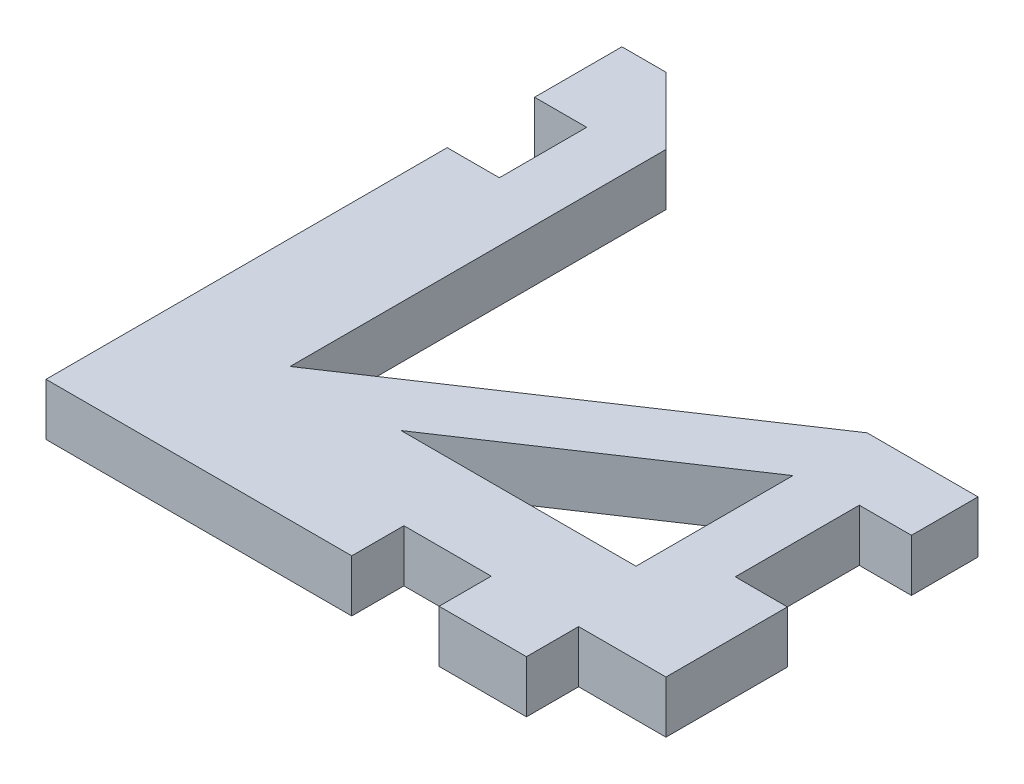
from build123d import *

# Parameters (mm, degrees)
BOSS_EXTRUDE1_DEPTH = 5.969
BOSS_EXTRUDE2_DEPTH = 5.969
SKETCH4_W           = 50.8
SKETCH4_H           = 43.029
CUT_EXTRUDE1_DEPTH  = 6.969
BOSS_EXTRUDE3_DEPTH = 5.969
BOSS_EXTRUDE5_DEPTH = 5.969
SKETCH8_W           = 10
SKETCH8_H           = 5.969
CUT_EXTRUDE2_DEPTH  = 6.969


with BuildPart() as part:
    # Sketch1 → Boss-Extrude1 (new body)
    with BuildSketch(Plane(origin=(0, 0, 0), x_dir=(1, 0, 0), z_dir=(0, 1, 0))):
        Polygon((0, 0), (-5.969, 0), (-5.969, 10), (0, 10), (0, 20), (-5.969, 20), (-5.969, 30), (-0.928040102, 30), (59.031, -29.959040102), (49.031, -29.959040102), (49.031, -35.928040102), (39.031, -35.928040102), (39.031, -29.959040102), (29.959040102, -29.959040102), align=None)
    extrude(amount=BOSS_EXTRUDE1_DEPTH)

    # Sketch3 → Boss-Extrude2 (add)
    with BuildSketch(Plane(origin=(0, 5.969, 0), x_dir=(1, 0, 0), z_dir=(0, 1, 0))):
        Polygon((6.731, -35.928040102), (29.959040102, -35.928040102), (29.959040102, -23.228040102), (6.731, 0), (-5.969, 0), (-5.969, -35.928040102), align=None)
    extrude(amount=-BOSS_EXTRUDE2_DEPTH)

    # Sketch4 → Cut-Extrude1 (cut, through all)
    with BuildSketch(Plane(origin=(0, 5.969, 0), x_dir=(1, 0, 0), z_dir=(0, 1, 0))):
        with Locations((32.131, 0.826459898)):
            Rectangle(SKETCH4_W, SKETCH4_H)
    extrude(amount=-CUT_EXTRUDE1_DEPTH, mode=Mode.SUBTRACT)

    # Sketch5 → Boss-Extrude3 (add)
    with BuildSketch(Plane(origin=(0, 5.969, 0), x_dir=(1, 0, 0), z_dir=(0, 1, 0))):
        Polygon((59.031, -29.959040102), (46.331, -20.688040102), (46.331, 5.760959898), (59.031, 5.760959898), (59.031, -1.859040102), (53.062, -1.859040102), (53.062, -16.059040102), (59.031, -16.059040102), align=None)
    extrude(amount=-BOSS_EXTRUDE3_DEPTH)

    # Sketch7 → Boss-Extrude5 (add)
    with BuildSketch(Plane(origin=(0, 5.969, 0), x_dir=(1, 0, 0), z_dir=(0, 1, 0))):
        Polygon((46.331, 5.760959898), (6.731, -20.688040102), (19.431, -20.688040102), (46.331, -2.721421415), align=None)
    extrude(amount=-BOSS_EXTRUDE5_DEPTH)

    # Sketch8 → Cut-Extrude2 (cut, through all)
    with BuildSketch(Plane(origin=(0, 5.969, 0), x_dir=(1, 0, 0), z_dir=(0, 1, 0))):
        with Locations((34.031, -32.943540102)):
            Rectangle(SKETCH8_W, SKETCH8_H)
    extrude(amount=-CUT_EXTRUDE2_DEPTH, mode=Mode.SUBTRACT)


solid = part.part
